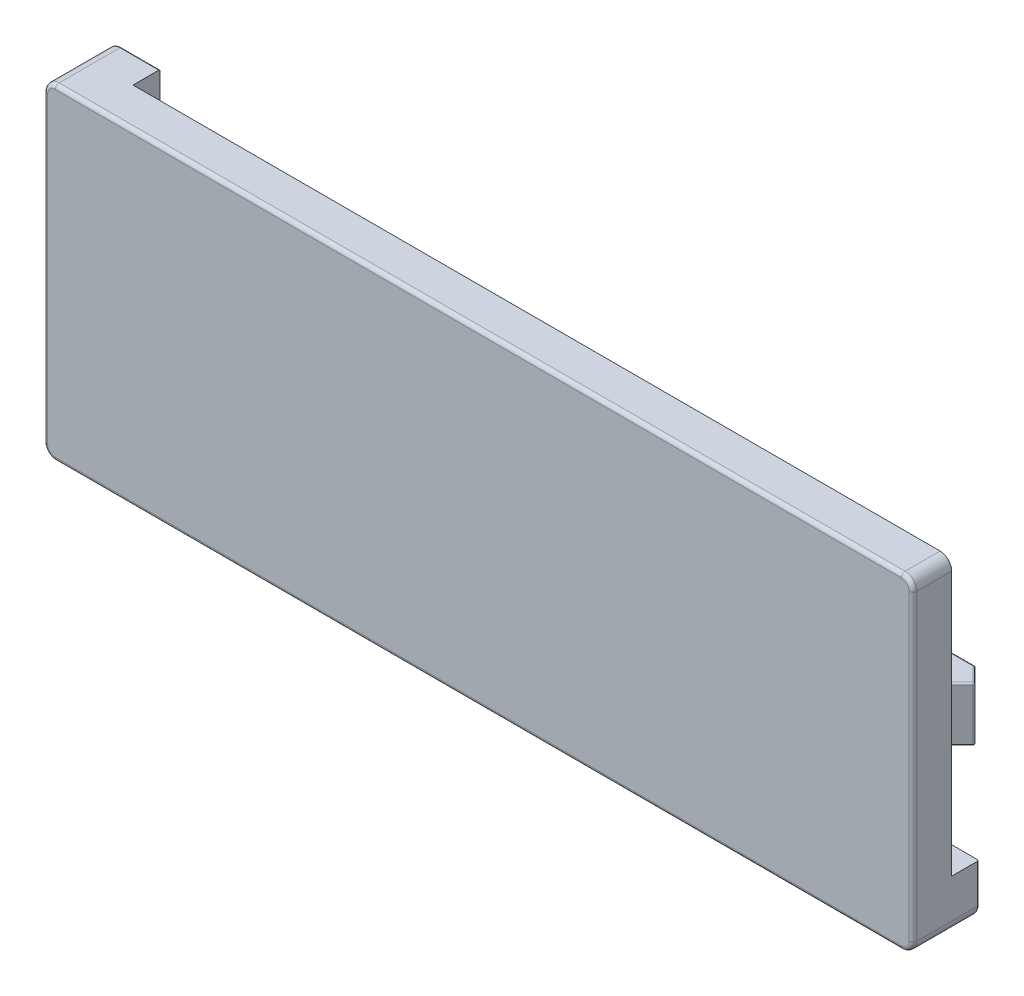
from build123d import *

# Parameters (mm, degrees)
SKETCH1_W            = 111.9
SKETCH1_H            = 42
BOSS_EXTRUDE1_DEPTH  = 5
SKETCH2_W            = 6.5
SKETCH2_H            = 6.5
BOSS_EXTRUDE2_DEPTH  = 3.5
CUT_EXTRUDE1_DEPTH   = 2
CUT_EXTRUDE2_DEPTH   = 2
BOSS_EXTRUDE3_DEPTH  = 3.5
FILLET1_R            = 0.2
FILLET1_OF_MIRROR1_R = 0.2
FILLET2_R            = 1.5
FILLET3_R            = 0.5
FILLET4_R            = 0.2
FILLET5_R            = 0.2
FILLET6_R            = 0.2


with BuildPart() as part:
    # Sketch1 → Boss-Extrude1 (new body)
    with BuildSketch(Plane.XY):
        Rectangle(SKETCH1_W, SKETCH1_H)
    extrude(amount=BOSS_EXTRUDE1_DEPTH)

    # Sketch2 → Boss-Extrude2 (add)
    with BuildSketch(Plane(origin=(0, 0, 0), x_dir=(-1, 0, 0), z_dir=(0, 0, -1))):
        with Locations((52.7, 17.75)):
            Rectangle(SKETCH2_W, SKETCH2_H)
        with Locations((-52.7, -17.75)):
            Rectangle(SKETCH2_W, SKETCH2_H)
    extrude(amount=BOSS_EXTRUDE2_DEPTH)

    # Sketch3 → Cut-Extrude1 (cut)
    with BuildSketch(Plane(origin=(0, 0, 0), x_dir=(-1, 0, 0), z_dir=(0, 0, -1))):
        Polygon((-45.45, -17), (51.95, -17), (51.95, 10.5), (45.45, 10.5), (45.45, 17), (-51.95, 17), (-51.95, -10.5), (-45.45, -10.5), align=None)
        Polygon((-42.45, -14), (48.95, -14), (48.95, 7.5), (42.45, 7.5), (42.45, 14), (-48.95, 14), (-48.95, -7.5), (-42.45, -7.5), align=None, mode=Mode.SUBTRACT)
    extrude(amount=-CUT_EXTRUDE1_DEPTH, mode=Mode.SUBTRACT)

    # Sketch5 → Cut-Extrude2 (cut)
    with BuildSketch(Plane(origin=(0, 0, 0), x_dir=(-1, 0, 0), z_dir=(0, 0, -1))):
        Polygon((-40.45, -12), (46.95, -12), (46.95, 5.5), (40.45, 5.5), (40.45, 12), (-46.95, 12), (-46.95, -5.5), (-40.45, -5.5), align=None)
    extrude(amount=-CUT_EXTRUDE2_DEPTH, mode=Mode.SUBTRACT)

    # Sketch6 → Boss-Extrude3 (add, symmetric)
    with BuildSketch(Plane(origin=(0, 0, 0), x_dir=(-1, 0, 0), z_dir=(0, -1, 0))):
        Polygon((53.95, 5), (51.95, 7), (48.95, 7), (48.95, 0), (48.95, -2), (51.95, -2), (51.95, 0), (51.95, 3), align=None)
    boss_extrude3 = extrude(amount=BOSS_EXTRUDE3_DEPTH, both=True)

    # Fillet1
    fillet1_edges = [part.edges().sort_by_distance(p)[0] for p in [
        (-51.95, 3.5, -1.5),
        (-48.95, 0, -7),
        (-52.95, 3.5, -6),
        (-53.95, 0, -5),
        (-50.45, 3.5, -7),
        (-51.95, 0, -7),
        (-52.95, 3.5, -4),
        (-51.95, 0, -3),
        (-48.95, 3.5, -3.5),
    ]]
    fillet(fillet1_edges, radius=FILLET1_R)

    # Mirror1: Boss-Extrude3 across plane
    add(boss_extrude3.mirror(Plane.ZY))

    # Fillet1 of Mirror1
    fillet1_of_mirror1_edges = [part.edges().sort_by_distance(p)[0] for p in [
        (51.95, 3.5, -1.5),
        (48.95, 0, -7),
        (52.95, 3.5, -6),
        (53.95, 0, -5),
        (50.45, 3.5, -7),
        (51.95, 0, -7),
        (52.95, 3.5, -4),
        (51.95, 0, -3),
        (48.95, 3.5, -3.5),
    ]]
    fillet(fillet1_of_mirror1_edges, radius=FILLET1_OF_MIRROR1_R)

    # Fillet2
    fillet2_edges = [part.edges().sort_by_distance(p)[0] for p in [
        (-55.95, 21, 0.75),
        (55.95, 21, 2.5),
        (55.95, -21, 0.75),
        (-55.95, -21, 2.5),
    ]]
    fillet(fillet2_edges, radius=FILLET2_R)

    # Fillet3
    fillet3_edges = [part.edges().sort_by_distance(p)[0] for p in [
        (0, -21, 5),
        (-55.95, 0, 5),
        (55.95, 0, 5),
        (0, 21, 5),
        (55.510660172, 20.560660172, 5),
        (55.510660172, -20.560660172, 5),
        (-55.510660172, 20.560660172, 5),
        (-55.510660172, -20.560660172, 5),
    ]]
    fillet(fillet3_edges, radius=FILLET3_R)

    # Fillet4
    fillet4_edges = [part.edges().sort_by_distance(p)[0] for p in [
        (43.7, -5.5, 2),
        (46.95, 3.25, 2),
        (3.25, 12, 2),
        (-40.45, 8.75, 2),
        (-43.7, 5.5, 2),
        (-46.95, -3.25, 2),
        (-3.25, -12, 2),
        (40.45, -8.75, 2),
        (3.25, 17, 2),
        (-45.45, 13.75, 2),
        (-48.7, 10.5, 2),
        (-51.95, 7, 2),
        (-50.45, 3.5, 2),
        (-48.95, 5.5, 2),
        (-45.7, 7.5, 2),
        (-42.45, 10.75, 2),
        (3.25, 14, 2),
        (48.95, 8.75, 2),
        (50.45, 3.5, 2),
        (51.95, 10.25, 2),
        (48.95, -5.5, 2),
        (45.7, -7.5, 2),
        (42.45, -10.75, 2),
        (-3.25, -14, 2),
        (-48.95, -8.75, 2),
        (-50.45, -3.5, 2),
        (-51.95, -10.25, 2),
        (-3.25, -17, 2),
        (45.45, -13.75, 2),
        (48.7, -10.5, 2),
        (51.95, -7, 2),
        (50.45, -3.5, 2),
        (51.95, -3.5, 1),
        (48.95, -3.5, 1),
        (51.95, 3.5, 1),
        (48.95, 3.5, 1),
        (-48.95, -3.5, 1),
        (-51.95, -3.5, 1),
        (-48.95, 3.5, 1),
        (-51.95, 3.5, 1),
        (-51.95, -17, 1),
    ]]
    fillet(fillet4_edges, radius=FILLET4_R)

    # Fillet5
    fillet5_edges = [part.edges().sort_by_distance(p)[0] for p in [
        (51.95, -3.5, -1.458578644),
        (51.965224093, -3.5, -2.993693974),
        (52.908578644, -3.5, -3.958578644),
        (53.867157288, -3.5, -5),
        (52.908578644, -3.5, -6.041421356),
        (51.943693974, -3.5, -6.984775907),
        (50.508578644, -3.5, -7),
        (49.008578644, -3.5, -6.941421356),
        (-51.95, -3.5, -1.458578644),
        (-51.965224093, -3.5, -2.993693974),
        (-52.908578644, -3.5, -3.958578644),
        (-53.867157288, -3.5, -5),
        (-52.908578644, -3.5, -6.041421356),
        (-51.943693974, -3.5, -6.984775907),
        (-50.508578644, -3.5, -7),
        (-49.008578644, -3.5, -6.941421356),
        (48.95, -3.5, -3.4),
        (-48.95, -3.5, -3.4),
    ]]
    fillet(fillet5_edges, radius=FILLET5_R)

    # Fillet6
    fillet6_edges = [part.edges().sort_by_distance(p)[0] for p in [
        (-55.95, 17, -3.5),
        (55.95, -17, -3.5),
        (51.95, -21, -3.5),
        (-51.95, 21, -3.5),
        (-55.510660172, 20.560660172, -3.5),
        (55.510660172, -20.560660172, -3.5),
    ]]
    fillet(fillet6_edges, radius=FILLET6_R)


solid = part.part
